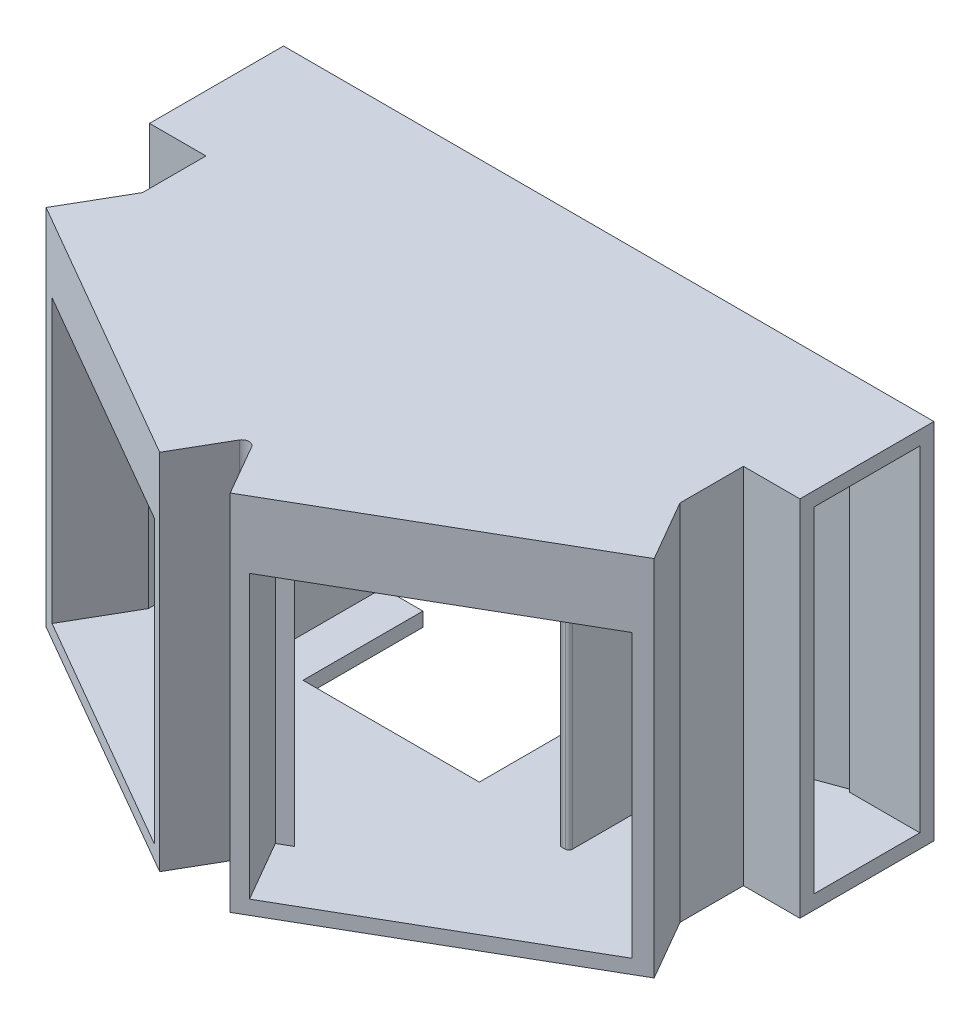
from build123d import *

# Parameters (mm, degrees)
SKETCH1_W                 = 76.21
SKETCH1_H                 = 51.5
BOSS_EXTRUDE1_DEPTH       = 25
SHELL1_T                  = -2
CUT_EXTRUDE1_DEPTH        = 53.345520582
SKETCH4_W                 = 43.999864015
SKETCH4_H                 = 51.5
SKETCH4_W_2               = 39.690462938
SKETCH4_H_2               = 47.5
BOSS_EXTRUDE2_DEPTH       = 10
BOSS_EXTRUDE3_REACH       = 75.765
FILLET1_R                 = 0.5
FILLET3_R                 = 6
FILLET1_OF_MIRROR3_R      = 0.5
FILLET3_OF_MIRROR3_R      = 6
CUT_EXTRUDE2_DEPTH        = 74.765193194
BOSS_EXTRUDE4_REACH       = 75.765
SKETCH7_W                 = 24.449300912
SKETCH7_H                 = 1.5
CUT_EXTRUDE3_REACH        = 79.215
LPATTERN1_COUNT           = 2
LPATTERN1_PITCH           = 8
SKETCH9_R                 = 2
SKETCH9_R_2               = 1.5
BOSS_EXTRUDE5_DEPTH       = 5
SKETCH10_W                = 4
SKETCH10_H                = 4
BOSS_EXTRUDE6_DEPTH       = 7
BOSS_EXTRUDE7_DEPTH       = 10.35
SKETCH12_R                = 2
BOSS_EXTRUDE8_DEPTH       = 10
F_1_5MM_DOWEL_HOLE1_D     = 1.5
F_1_5MM_DOWEL_HOLE1_DEPTH = 5
F_1_5MM_DOWEL_HOLE1_TIP   = 0.450645464
FILLET5_R                 = 1
SKETCH15_W                = 19
SKETCH15_H                = 51.5
SKETCH15_W_2              = 15
SKETCH15_H_2              = 47.5
BOSS_EXTRUDE9_DEPTH       = 10
CUT_EXTRUDE4_REACH        = 91.835
SKETCH16_W                = 15
SKETCH16_H                = 47.5
BOSS_EXTRUDE10_REACH      = 91.93
SKETCH19_W                = 10
SKETCH19_H                = 7.5


with BuildPart() as part:
    # Sketch1 → Boss-Extrude1 (new, symmetric)
    with BuildSketch(Plane.XY):
        Rectangle(SKETCH1_W, SKETCH1_H)
    extrude(amount=BOSS_EXTRUDE1_DEPTH, both=True)

    # Shell1
    shell1_openings = [part.faces().sort_by_distance(p)[0] for p in [
        (0, 0, -25),
    ]]
    offset(amount=SHELL1_T, openings=shell1_openings, kind=Kind.INTERSECTION)

    # Sketch3 → Cut-Extrude1 (cut, symmetric)
    with BuildSketch(Plane(origin=(0, 0, 0), x_dir=(1, 0, 0), z_dir=(0, 1, 0))):
        Polygon((0, -25), (-38.105, -3.000067993), (-38.105, -25), align=None)
    cut_extrude1 = extrude(amount=CUT_EXTRUDE1_DEPTH, both=True, mode=Mode.SUBTRACT)

    # Mirror1: Cut-Extrude1 across plane
    add(cut_extrude1.mirror(Plane(origin=(0, 0, 0), x_dir=(0, 0, 1), z_dir=(1, 0, 0))), mode=Mode.SUBTRACT)

    # Sketch4 → Boss-Extrude2 (add)
    with BuildSketch(Plane(origin=(-10.825317547, 0, 18.75), x_dir=(0.8660254037844363, 0, 0.5000000000000042), z_dir=(-0.5000000000000041, 0, 0.8660254037844362))):
        with Locations((-9.499932008, 0)):
            Rectangle(SKETCH4_W, SKETCH4_H)
        with Locations((-9.345231469, 0)):
            Rectangle(SKETCH4_W_2, SKETCH4_H_2, mode=Mode.SUBTRACT)
    boss_extrude2 = extrude(amount=BOSS_EXTRUDE2_DEPTH)

    # Mirror2: Boss-Extrude2 across plane
    add(boss_extrude2.mirror(Plane(origin=(0, 0, 0), x_dir=(0, 0, 1), z_dir=(1, 0, 0))))

    # Sketch5 → Boss-Extrude3 (add, up to next)
    with BuildSketch(Plane(origin=(0, -23.75, 0), x_dir=(1, 0, 0), z_dir=(0, 1, 0)), mode=Mode.PRIVATE) as boss_extrude3_sk1:
        Polygon((-22, 19.866199846), (-36.105, 25), (-36.105, 23.5), (-23.5, 18.912155197), (-23.5, -4.154768531), (-22, -4.154768531), align=None)
    boss_extrude3_tool1 = extrude(boss_extrude3_sk1.sketch, amount=BOSS_EXTRUDE3_REACH, mode=Mode.PRIVATE) - part.part
    boss_extrude3 = boss_extrude3_tool1.solids().sort_by_distance((-29.163272, -23.75, -22.128757))[0]
    add(boss_extrude3)

    # Fillet1
    fillet1_edges = [part.edges().sort_by_distance(p)[0] for p in [
        (-22, 0, 4.154768531),
        (-23.5, 0, 4.154768531),
    ]]
    fillet(fillet1_edges, radius=FILLET1_R)

    # Fillet3
    fillet3_edges = [part.edges().sort_by_distance(p)[0] for p in [
        (-22, 0, -19.866199846),
        (-23.5, 0, -18.912155197),
    ]]
    fillet(fillet3_edges, radius=FILLET3_R)

    # Mirror3: Boss-Extrude3 across plane
    add(boss_extrude3.mirror(Plane(origin=(0, 0, 0), x_dir=(0, 0, 1), z_dir=(1, 0, 0))))

    # Fillet1 of Mirror3
    fillet1_of_mirror3_edges = [part.edges().sort_by_distance(p)[0] for p in [
        (22, 0, 4.154768531),
        (23.5, 0, 4.154768531),
    ]]
    fillet(fillet1_of_mirror3_edges, radius=FILLET1_OF_MIRROR3_R)

    # Fillet3 of Mirror3
    fillet3_of_mirror3_edges = [part.edges().sort_by_distance(p)[0] for p in [
        (22, 0, -19.866199846),
        (23.5, 0, -18.912155197),
    ]]
    fillet(fillet3_of_mirror3_edges, radius=FILLET3_OF_MIRROR3_R)

    # Sketch6 → Cut-Extrude2 (cut, through all)
    with BuildSketch(Plane(origin=(0, -23.75, 0), x_dir=(1, 0, 0), z_dir=(0, 1, 0))):
        Polygon((-28.344300912, 25), (11.655699088, 25), (11.655699088, 15), (8.655699088, 15), (8.655699088, -2), (-16.344300912, -2), (-16.344300912, 15), (-28.344300912, 15), align=None)
    extrude(amount=-CUT_EXTRUDE2_DEPTH, mode=Mode.SUBTRACT)

    # Sketch7 → Boss-Extrude4 (add, up to next)
    with BuildSketch(Plane(origin=(0, -23.75, 0), x_dir=(1, 0, 0), z_dir=(0, 1, 0)), mode=Mode.PRIVATE) as boss_extrude4_sk1:
        with Locations((23.880349544, 24.25)):
            Rectangle(SKETCH7_W, SKETCH7_H)
    boss_extrude4_tool1 = extrude(boss_extrude4_sk1.sketch, amount=BOSS_EXTRUDE4_REACH, mode=Mode.PRIVATE) - part.part
    add(boss_extrude4_tool1.solids().sort_by_distance((23.88035, -23.75, -24.25))[0])

    # Sketch8 → Cut-Extrude3 (cut, up to next)
    with BuildSketch(Plane(origin=(0, 0, -25), x_dir=(-1, 0, 0), z_dir=(0, 0, -1)), mode=Mode.PRIVATE) as cut_extrude3_sk1:
        with BuildLine():
            Line((-14.655699088, 19), (-14.655699088, -21))
            ThreePointArc((-14.655699088, -21), (-16.655699088, -23), (-18.655699088, -21))
            Line((-18.655699088, -21), (-18.655699088, 19))
            ThreePointArc((-18.655699088, 19), (-16.655699088, 21), (-14.655699088, 19))
        make_face()
    cut_extrude3_tool1 = extrude(cut_extrude3_sk1.sketch, amount=-CUT_EXTRUDE3_REACH, mode=Mode.PRIVATE) & part.part
    cut_extrude3 = cut_extrude3_tool1.solids().sort_by_distance((16.655699, -1, -25))[0]
    add(cut_extrude3, mode=Mode.SUBTRACT)

    # LPattern1: Cut-Extrude3 ×2
    with Locations(*[(i * LPATTERN1_PITCH, 0, 0) for i in range(1, LPATTERN1_COUNT)]):
        add(cut_extrude3, mode=Mode.SUBTRACT)



with BuildPart() as body_2:
    # Sketch9 → Boss-Extrude5 (new body)
    with BuildSketch(Plane(origin=(0, 0, -25), x_dir=(-1, 0, 0), z_dir=(0, 0, -1))):
        with Locations((21.844300912, 11.4)):
            Circle(SKETCH9_R)
        with Locations((21.844300912, 11.4)):
            Circle(SKETCH9_R_2, mode=Mode.SUBTRACT)
    extrude(amount=-BOSS_EXTRUDE5_DEPTH)

    # Sketch10 → Boss-Extrude6 (add)
    with BuildSketch(Plane.XY.offset(-20)):
        with Locations((-21.844300912, 11.4)):
            Rectangle(SKETCH10_W, SKETCH10_H)
    extrude(amount=BOSS_EXTRUDE6_DEPTH)


with BuildPart() as part_1:
    add(part.part)

    add(body_2.part)  # Boss-Extrude7 merges body 2
    # Sketch11 → Boss-Extrude7 (add)
    with BuildSketch(Plane(origin=(0, 13.4, 0), x_dir=(1, 0, 0), z_dir=(0, 1, 0))):
        Polygon((-19.844300912, 20), (-21.844300912, 20), (-23.844300912, 20), (-23.844300912, 13), (-19.844300912, 13), align=None)
    extrude(amount=BOSS_EXTRUDE7_DEPTH)

    # Sketch12 → Boss-Extrude8 (add)
    with BuildSketch(Plane(origin=(0, 0, -25), x_dir=(-1, 0, 0), z_dir=(0, 0, -1))):
        with Locations((39.344300912, -7.5)):
            Circle(SKETCH12_R)
    extrude(amount=-BOSS_EXTRUDE8_DEPTH)

    # Ø1.5mm Dowel Hole1
    with Locations(Plane(origin=(0, 0, -25), x_dir=(-1, 0, 0), z_dir=(0, 0, -1))):
        with Locations((39.344300912, -7.5)):
            Hole(F_1_5MM_DOWEL_HOLE1_D / 2, depth=F_1_5MM_DOWEL_HOLE1_DEPTH)
            with Locations((0, 0, -(F_1_5MM_DOWEL_HOLE1_DEPTH + F_1_5MM_DOWEL_HOLE1_TIP / 2))):  # 118° drill point
                Cone(0, F_1_5MM_DOWEL_HOLE1_D / 2, F_1_5MM_DOWEL_HOLE1_TIP, mode=Mode.SUBTRACT)

    # Fillet5
    fillet5_edges = [part_1.edges().sort_by_distance(p)[0] for p in [
        (0, 0, 25),
    ]]
    fillet(fillet5_edges, radius=FILLET5_R)

    # Sketch15 → Boss-Extrude9 (add)
    with BuildSketch(Plane.ZY.offset(-36.105)):
        with Locations((-15.5, 0)):
            Rectangle(SKETCH15_W, SKETCH15_H)
        with Locations((-15.5, 0)):
            Rectangle(SKETCH15_W_2, SKETCH15_H_2, mode=Mode.SUBTRACT)
    boss_extrude9 = extrude(amount=-BOSS_EXTRUDE9_DEPTH)

    # Sketch16 → Cut-Extrude4 (cut, up to next)
    with BuildSketch(Plane.ZY.offset(-36.105), mode=Mode.PRIVATE) as cut_extrude4_sk1:
        with Locations((-15.5, 0)):
            Rectangle(SKETCH16_W, SKETCH16_H)
    cut_extrude4_tool1 = extrude(cut_extrude4_sk1.sketch, amount=-CUT_EXTRUDE4_REACH, mode=Mode.PRIVATE) & part_1.part
    cut_extrude4 = cut_extrude4_tool1.solids().sort_by_distance((36.105, 0, -15.5))[0]
    add(cut_extrude4, mode=Mode.SUBTRACT)

    # Mirror4: Boss-Extrude9, Cut-Extrude4 mirrored; each copy of Cut-Extrude4 runs up to whatever stops it at its own place
    mirror4_before = part_1.part  # the part as the pattern finds it: every copy runs up to it
    add(boss_extrude9.mirror(Plane(origin=(0, 0, 0), x_dir=(0, 0, 1), z_dir=(1, 0, 0))))
    mirror4_cut_extrude4_long = extrude(cut_extrude4_sk1.sketch, amount=-CUT_EXTRUDE4_REACH, mode=Mode.PRIVATE)
    mirror4_cut_extrude4_tool = mirror4_cut_extrude4_long.mirror(Plane(origin=(0, 0, 0), x_dir=(0, 0, 1), z_dir=(1, 0, 0))) & mirror4_before
    add(mirror4_cut_extrude4_tool.solids().sort_by_distance((-36.105, 0, -15.5))[0], mode=Mode.SUBTRACT)

    # Sketch19 → Boss-Extrude10 (add, up to next)
    with BuildSketch(Plane(origin=(-25.279682453, 0, -14.595231469), x_dir=(0.5000000000000041, 0, -0.8660254037844364), z_dir=(0.8660254037844364, 0, 0.5000000000000041)), mode=Mode.PRIVATE) as boss_extrude10_sk1:
        with Locations((-26.650635095, 20)):
            Rectangle(SKETCH19_W, SKETCH19_H)
    boss_extrude10_tool1 = extrude(boss_extrude10_sk1.sketch, amount=BOSS_EXTRUDE10_REACH, mode=Mode.PRIVATE) - part_1.part
    boss_extrude10 = boss_extrude10_tool1.solids().sort_by_distance((-38.605, 20, 8.484896))[0]
    add(boss_extrude10)

    # Mirror5: Boss-Extrude10 across plane
    add(boss_extrude10.mirror(Plane(origin=(0, 0, 0), x_dir=(0, 0, 1), z_dir=(1, 0, 0))))


solid = part_1.part
